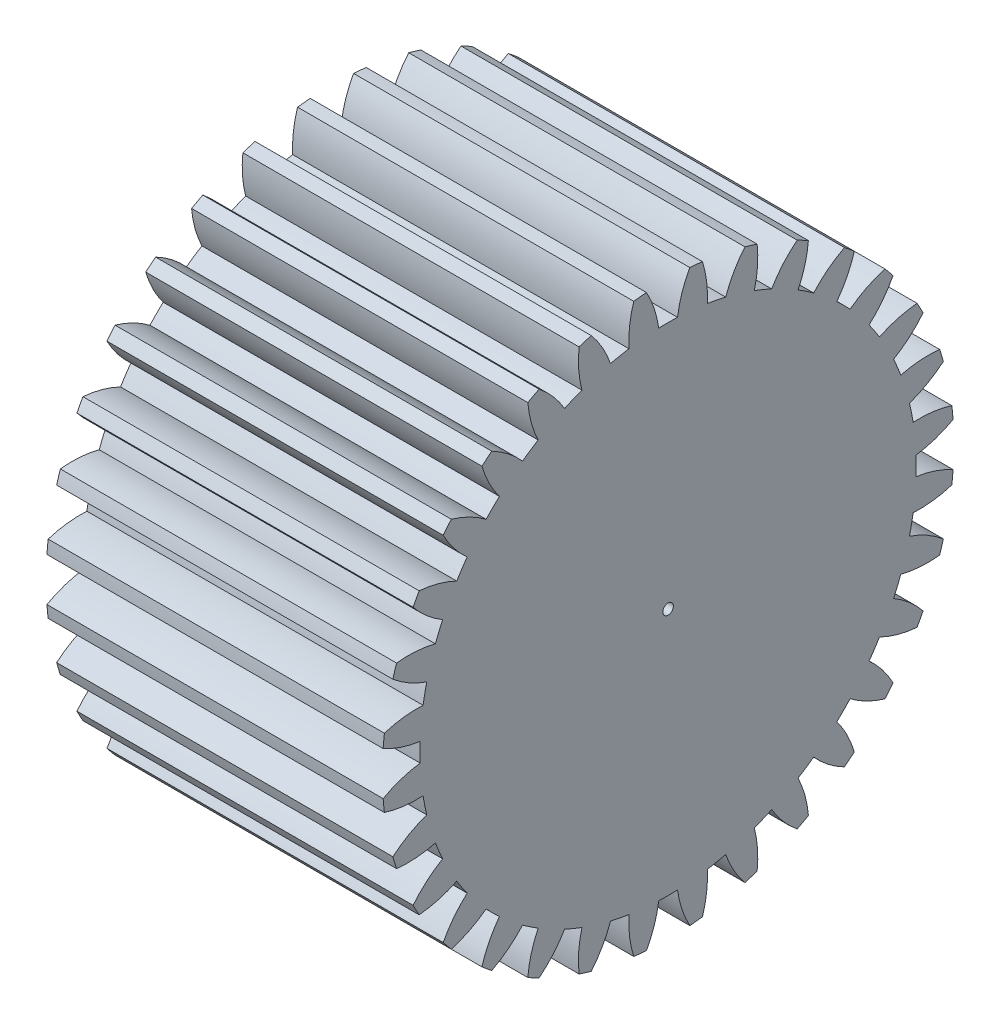
from build123d import *

# Parameters (mm, degrees)
BASPROSKE_W     = 25.4
BASPROSKE_H     = 21.59
TOOTHCUT_DEPTH  = 40.716699259
TEETHCUTS_COUNT = 32
TEETHCUTS_ANGLE = 348.75
BORSKE_R        = 0.396875
BORE_DEPTH      = 50.8000508


with BuildPart() as part:
    # BasProSke → Base-Revolve (revolve)
    with BuildSketch(Plane(origin=(0, 0, 0), x_dir=(1, 0, 0), z_dir=(0, 1, 0)), mode=Mode.PRIVATE) as base_revolve_sk:
        with Locations((12.7, 10.795)):
            Rectangle(BASPROSKE_W, BASPROSKE_H)
    revolve(base_revolve_sk.sketch.rotate(Axis((-10, 0, 0), (1, 0, 0)), 180), axis=Axis((-10, 0, 0), (1, 0, 0)))

    # TooCutSke → ToothCut (cut, through all)
    with BuildSketch(Plane(origin=(0, 0, 0), x_dir=(0, 0, -1), z_dir=(1, 0, 0))):
        with BuildLine():
            ThreePointArc((0.709775581, 18.73175757), (0, 18.7452), (-0.709775581, 18.73175757))
            ThreePointArc((-0.709775581, 18.73175757), (-1.0499335, 20.185403862), (-1.650224462, 21.552314873))
            ThreePointArc((-1.650224462, 21.552314873), (0, 21.6154), (1.650224462, 21.552314873))
            ThreePointArc((1.650224462, 21.552314873), (1.0499335, 20.185403862), (0.709775581, 18.73175757))
        make_face()
    toothcut = extrude(amount=TOOTHCUT_DEPTH, mode=Mode.SUBTRACT)

    # TeethCuts: ToothCut ×32 about axis
    teethcuts_axis = Axis((-10, 0, 0), (1, 0, 0))
    for i in range(1, TEETHCUTS_COUNT):
        add(toothcut.rotate(teethcuts_axis, i * TEETHCUTS_ANGLE / (TEETHCUTS_COUNT - 1)), mode=Mode.SUBTRACT)

    # BorSke → Bore (cut, symmetric)
    with BuildSketch(Plane(origin=(0, 0, 0), x_dir=(0, 0, -1), z_dir=(1, 0, 0))):
        with Locations(Location((0, 0, 0), (0, 0, 180))):
            Circle(BORSKE_R)
    extrude(amount=BORE_DEPTH, both=True, mode=Mode.SUBTRACT)


solid = part.part
